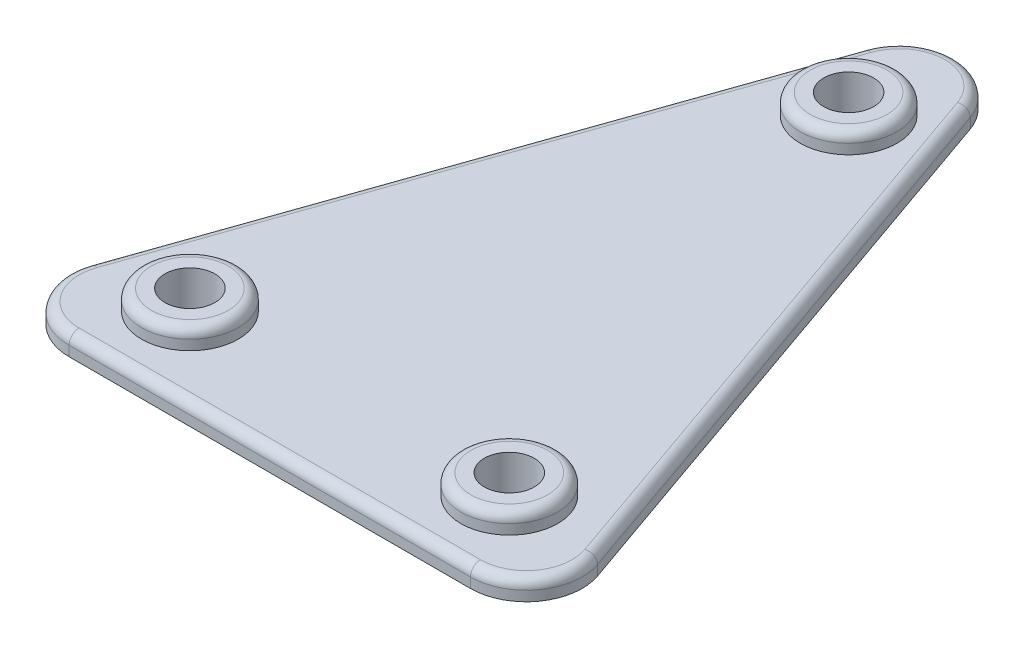
from build123d import *

# Parameters (mm, degrees)
BOSS_EXTRUDE1_DEPTH     = 1
BOSS_EXTRUDE3_START     = 1
SKETCH2_R               = 2.425
BOSS_EXTRUDE3_DEPTH     = 1
SKETCH3_R               = 1.25
CUT_EXTRUDE2_DEPTH      = 3
CUT_EXTRUDE2_DEPTH_BACK = 1
FILLET2_R               = 2.8
FILLET3_R               = 0.5


with BuildPart() as part:
    # Sketch1 → Boss-Extrude1 (new body)
    with BuildSketch(Plane(origin=(0, 0, 0), x_dir=(1, 0, 0), z_dir=(0, 1, 0))):
        Polygon((14, 0), (-14, 0), (0, 40), align=None)
    extrude(amount=BOSS_EXTRUDE1_DEPTH)

    # Sketch2 → Boss-Extrude3 (add)
    with BuildSketch(Plane(origin=(0, 0, 0), x_dir=(1, 0, 0), z_dir=(0, 1, 0)).offset(BOSS_EXTRUDE3_START)):
        with Locations((-8, 4)):
            Circle(SKETCH2_R)
        with Locations((0, 29)):
            Circle(SKETCH2_R)
        with Locations((8, 4)):
            Circle(SKETCH2_R)
    extrude(amount=BOSS_EXTRUDE3_DEPTH)

    # Sketch3 → Cut-Extrude2 (cut, two sides)
    with BuildSketch(Plane(origin=(0, 0, 0), x_dir=(1, 0, 0), z_dir=(0, 1, 0))) as cut_extrude2_sk:
        with Locations((0, 29)):
            Circle(SKETCH3_R)
        with Locations((-8, 4)):
            Circle(SKETCH3_R)
        with Locations((8, 4)):
            Circle(SKETCH3_R)
    extrude(amount=CUT_EXTRUDE2_DEPTH, mode=Mode.SUBTRACT)
    extrude(cut_extrude2_sk.sketch, amount=-CUT_EXTRUDE2_DEPTH_BACK, mode=Mode.SUBTRACT)

    # Fillet2
    fillet2_edges = [part.edges().sort_by_distance(p)[0] for p in [
        (0, 0.5, -40),
        (14, 0.5, 0),
        (-14, 0.5, 0),
    ]]
    fillet(fillet2_edges, radius=FILLET2_R)

    # Fillet3
    fillet3_edges = [part.edges().sort_by_distance(p)[0] for p in [
        (-10.425, 2, -4),
        (-2.425, 2, -29),
        (5.575, 2, -4),
        (-7.669529991, 1, -18.087057169),
        (7.669529991, 1, -18.087057169),
        (0, 1, 0),
        (-12.337084869, 1, -1.179806698),
        (12.337084869, 1, -1.179806698),
        (0, 1, -34.32415196),
    ]]
    fillet(fillet3_edges, radius=FILLET3_R)


solid = part.part
